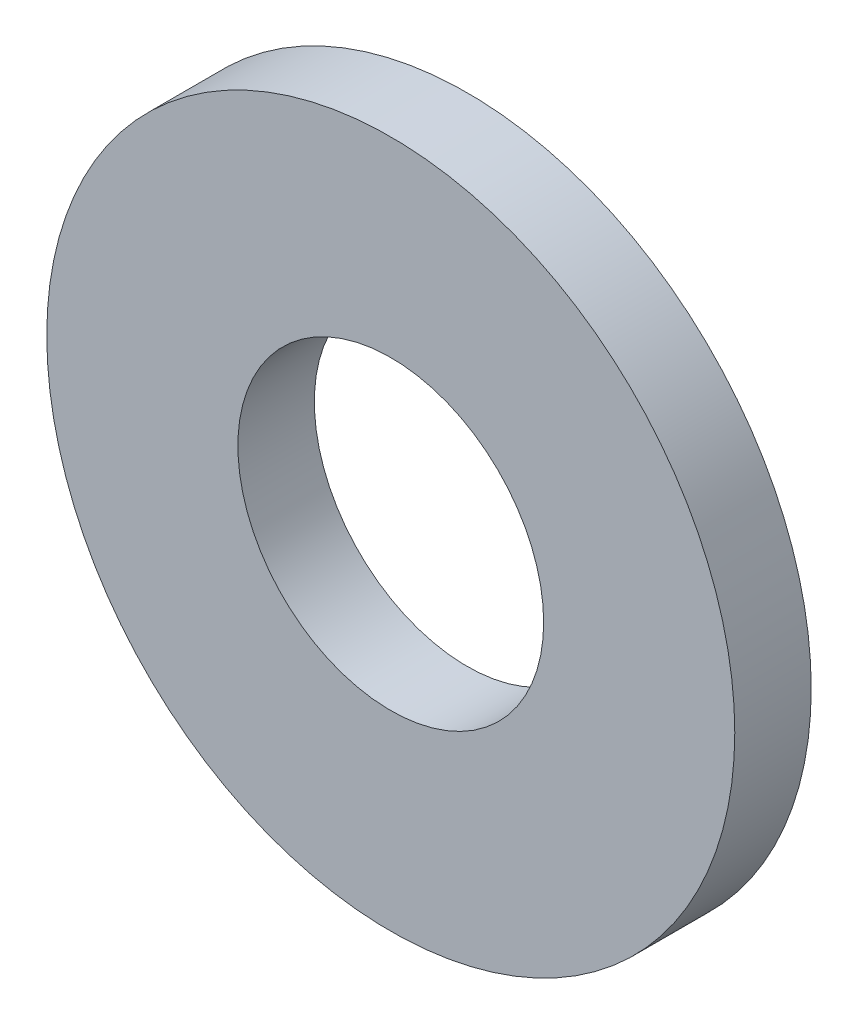
from build123d import *

# Parameters (mm, degrees)
SKETCH1_R           = 7.14375
SKETCH1_R_2         = 3.175
BOSS_EXTRUDE1_DEPTH = 1.5875


with BuildPart() as part:
    # Sketch1 → Boss-Extrude1 (new body)
    with BuildSketch(Plane.XY):
        Circle(SKETCH1_R)
        Circle(SKETCH1_R_2, mode=Mode.SUBTRACT)
    extrude(amount=BOSS_EXTRUDE1_DEPTH)


solid = part.part
